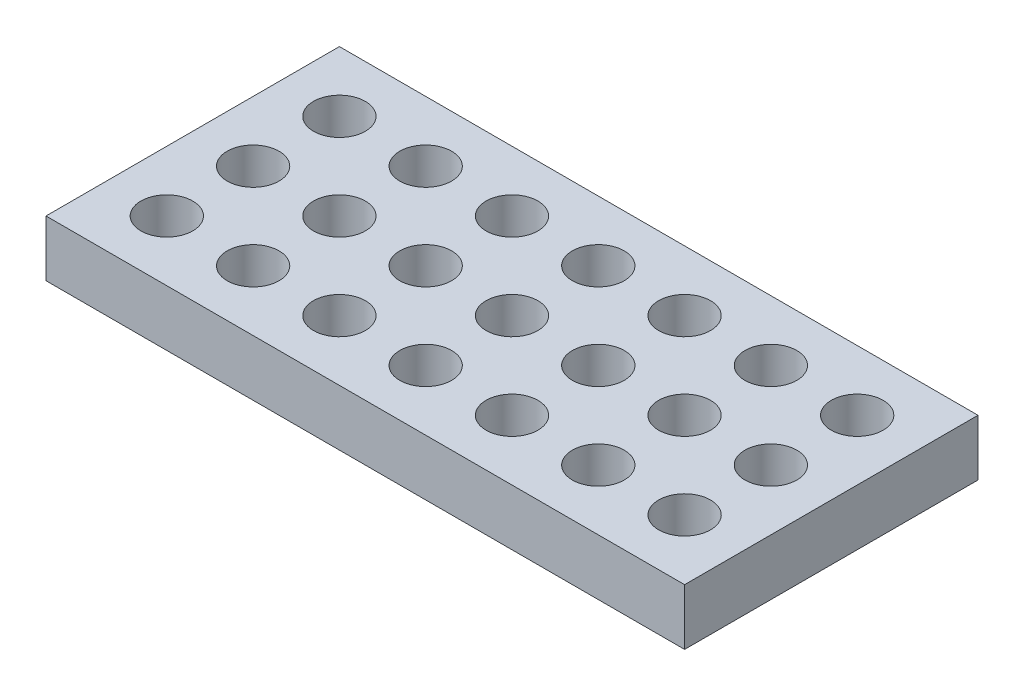
from build123d import *

# Parameters (mm, degrees)
SKETCH1_W           = 37
SKETCH1_H           = 17
SKETCH1_R           = 1.5025
BOSS_EXTRUDE1_DEPTH = 3.25


with BuildPart() as part:
    # Sketch1 → Boss-Extrude1 (new body)
    with BuildSketch(Plane(origin=(0, 0, 0), x_dir=(1, 0, 0), z_dir=(0, 1, 0))):
        Rectangle(SKETCH1_W, SKETCH1_H)
        with Locations((-15, -5)):
            Circle(SKETCH1_R, mode=Mode.SUBTRACT)
        with Locations((-10, -5)):
            Circle(SKETCH1_R, mode=Mode.SUBTRACT)
        with Locations((-5, -5)):
            Circle(SKETCH1_R, mode=Mode.SUBTRACT)
        with Locations((0, -5)):
            Circle(SKETCH1_R, mode=Mode.SUBTRACT)
        with Locations((5, -5)):
            Circle(SKETCH1_R, mode=Mode.SUBTRACT)
        with Locations((10, -5)):
            Circle(SKETCH1_R, mode=Mode.SUBTRACT)
        with Locations((15, -5)):
            Circle(SKETCH1_R, mode=Mode.SUBTRACT)
        with Locations((-10, 0)):
            Circle(SKETCH1_R, mode=Mode.SUBTRACT)
        with Locations((-5, 0)):
            Circle(SKETCH1_R, mode=Mode.SUBTRACT)
        Circle(SKETCH1_R, mode=Mode.SUBTRACT)
        with Locations((5, 0)):
            Circle(SKETCH1_R, mode=Mode.SUBTRACT)
        with Locations((10, 0)):
            Circle(SKETCH1_R, mode=Mode.SUBTRACT)
        with Locations((15, 0)):
            Circle(SKETCH1_R, mode=Mode.SUBTRACT)
        with Locations((-10, 5)):
            Circle(SKETCH1_R, mode=Mode.SUBTRACT)
        with Locations((-5, 5)):
            Circle(SKETCH1_R, mode=Mode.SUBTRACT)
        with Locations((0, 5)):
            Circle(SKETCH1_R, mode=Mode.SUBTRACT)
        with Locations((5, 5)):
            Circle(SKETCH1_R, mode=Mode.SUBTRACT)
        with Locations((10, 5)):
            Circle(SKETCH1_R, mode=Mode.SUBTRACT)
        with Locations((15, 5)):
            Circle(SKETCH1_R, mode=Mode.SUBTRACT)
        with Locations((-15, 0)):
            Circle(SKETCH1_R, mode=Mode.SUBTRACT)
        with Locations((-15, 5)):
            Circle(SKETCH1_R, mode=Mode.SUBTRACT)
    extrude(amount=BOSS_EXTRUDE1_DEPTH)


solid = part.part
